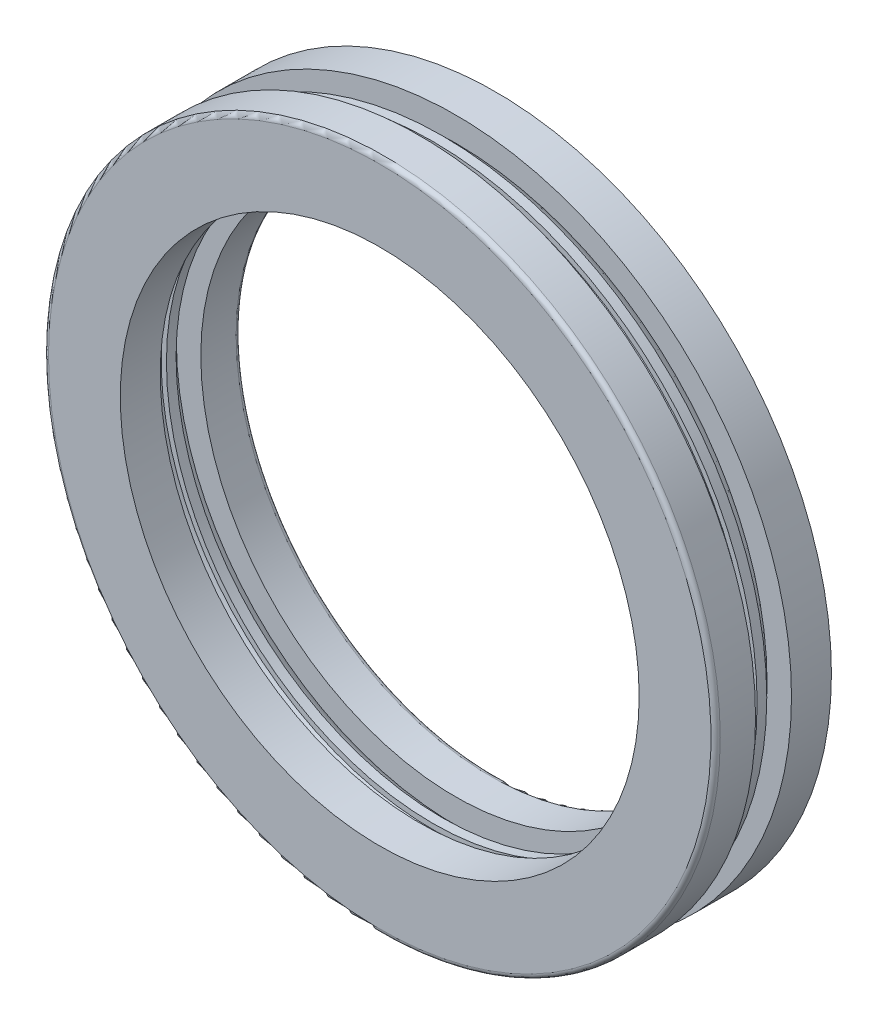
from build123d import *
from build123d.topology import SkipClean

# Parameters (mm, degrees)
FILLET1_R       = 1
CAGESKE_W       = 2.083334
CAGESKE_H       = 12.5
SIMPLIFIEDSKE_R = 5.208333


with BuildPart() as part:
    # BaseSke → Ball (revolve)
    with BuildSketch(Plane(origin=(0, 0, 0), x_dir=(0, 0, -1), z_dir=(1, 0, 0))):
        with BuildLine():
            Line((0, 68.958333), (0, 58.541667))
            ThreePointArc((0, 58.541667), (-5.208333, 63.75), (0, 68.958333))
        make_face()
    revolve(axis=Axis((0, 68.958333, 0), (0, -1, 0)))

    # InnerRaceSke → InnerRace (revolve)
    with BuildSketch(Plane(origin=(0, 0, 0), x_dir=(0, 0, -1), z_dir=(1, 0, 0)), mode=Mode.PRIVATE) as innerrace_sk:
        with BuildLine():
            Line((3.87931, 60.289708), (3.87931, 55))
            Line((3.87931, 55), (12.5, 55))
            Line((12.5, 55), (12.5, 72.5))
            Line((12.5, 72.5), (3.87931, 72.5))
            Line((3.87931, 72.5), (3.87931, 67.210292))
            ThreePointArc((3.87931, 67.210292), (5.198333, 63.75), (3.87931, 60.289708))
        make_face()
    revolve(innerrace_sk.sketch.rotate(Axis((0, 0, 18.959038), (0, 0, -1)), 90), axis=Axis((0, 0, 18.959038), (0, 0, -1)))

    # OuterRaceSke → OuterRace (revolve)
    with BuildSketch(Plane(origin=(0, 0, 0), x_dir=(0, 0, -1), z_dir=(1, 0, 0)), mode=Mode.PRIVATE) as outerrace_sk:
        with BuildLine():
            Line((-3.87931, 60.289708), (-3.87931, 56))
            Line((-3.87931, 56), (-12.5, 56))
            Line((-12.5, 56), (-12.5, 72.5))
            Line((-12.5, 72.5), (-3.87931, 72.5))
            Line((-3.87931, 72.5), (-3.87931, 67.210292))
            ThreePointArc((-3.87931, 67.210292), (-5.198333, 63.75), (-3.87931, 60.289708))
        make_face()
    revolve(outerrace_sk.sketch.rotate(Axis((0, 0, 27.164344), (0, 0, -1)), 90), axis=Axis((0, 0, 27.164344), (0, 0, -1)))

    # Fillet1
    fillet1_edges = [part.edges().sort_by_distance(p)[0] for p in [
        (-72.5, 0, 12.5),
        (-55, 0, -12.5),
    ]]
    fillet(fillet1_edges, radius=FILLET1_R)

    # CageSke → Cage (revolve)
    with SkipClean():  # the faces are left unmerged after this step: merging them gives an invalid solid
        with BuildSketch(Plane(origin=(0, 0, 0), x_dir=(0, 0, -1), z_dir=(1, 0, 0)), mode=Mode.PRIVATE) as cage_sk:
            with Locations((0, 63.75)):
                Rectangle(CAGESKE_W, CAGESKE_H)
        revolve(cage_sk.sketch.rotate(Axis((0, 0, 23.07703), (0, 0, -1)), 90), axis=Axis((0, 0, 23.07703), (0, 0, -1)))

    # SimplifiedSke → Simplified (revolve)
    with BuildSketch(Plane(origin=(0, 0, 0), x_dir=(0, 0, -1), z_dir=(1, 0, 0)), mode=Mode.PRIVATE) as simplified_sk:
        with Locations((0, 63.75)):
            Circle(SIMPLIFIEDSKE_R)
    revolve(simplified_sk.sketch.rotate(Axis((0, 0, 32.353574), (0, 0, -1)), 90), axis=Axis((0, 0, 32.353574), (0, 0, -1)))


solid = part.part
